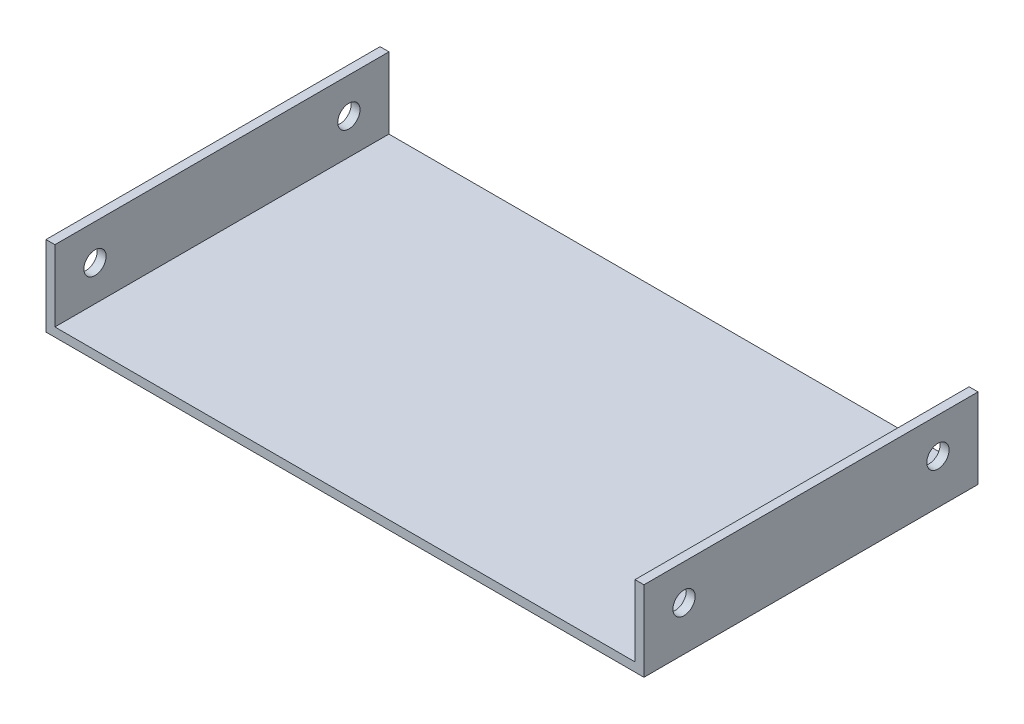
from build123d import *

# Parameters (mm, degrees)
ESBO_O1_W                = 130.25
ESBO_O1_H                = 75
RESSALTO_EXTRUS_O1_DEPTH = 2
ESBO_O2_W                = 75
ESBO_O2_H                = 18
RESSALTO_EXTRUS_O2_DEPTH = 2
ESBO_O3_R                = 2.5
CORTE_EXTRUS_O1_DEPTH    = 135.25


with BuildPart() as part:
    # Esboço1 → Ressalto-extrusão1 (new body)
    with BuildSketch(Plane(origin=(0, 0, 0), x_dir=(1, 0, 0), z_dir=(0, 1, 0))):
        Rectangle(ESBO_O1_W, ESBO_O1_H)
    extrude(amount=RESSALTO_EXTRUS_O1_DEPTH)

    # Esboço2 → Ressalto-extrusão2 (add)
    with BuildSketch(Plane(origin=(65.125, 0, 0), x_dir=(0, 0, -1), z_dir=(1, 0, 0))):
        with Locations((0, 9)):
            Rectangle(ESBO_O2_W, ESBO_O2_H)
    ressalto_extrus_o2 = extrude(amount=RESSALTO_EXTRUS_O2_DEPTH)

    # Espelhar1: Ressalto-extrusão2 across plane
    add(ressalto_extrus_o2.mirror(Plane(origin=(0, 0, 0), x_dir=(0, 0, 1), z_dir=(1, 0, 0))))

    # Esboço3 → Corte-extrusão1 (cut, through all)
    with BuildSketch(Plane.ZY.offset(67.125)):
        with Locations((-28.5, 10)):
            Circle(ESBO_O3_R)
        with Locations((28.5, 10)):
            Circle(ESBO_O3_R)
    extrude(amount=-CORTE_EXTRUS_O1_DEPTH, mode=Mode.SUBTRACT)


solid = part.part
